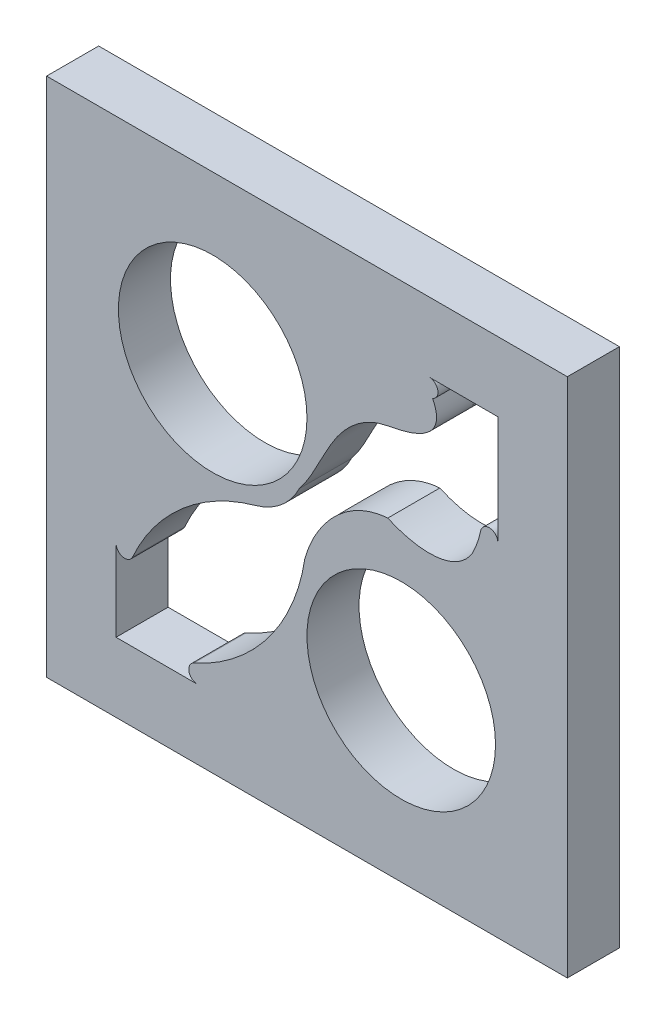
from build123d import *

# Parameters (mm, degrees)
CROQUIS1_W              = 30
CROQUIS1_H              = 30
CROQUIS1_R              = 5.43144852
SALIENTE_EXTRUIR1_DEPTH = 3


with BuildPart() as part:
    # Croquis1 → Saliente-Extruir1 (new body)
    with BuildSketch(Plane.XY):
        Rectangle(CROQUIS1_W, CROQUIS1_H)
        with Locations((5.43144852, -5.43144852)):
            Circle(CROQUIS1_R, mode=Mode.SUBTRACT)
        with BuildLine():
            Line((-11, -11), (-11, -6.30958424))
            ThreePointArc((-11, -6.30958424), (-10.604257207, -6.798593887), (-10.043478261, -6.51351536))
            ThreePointArc((-10.043478261, -6.51351536), (-7.184032198, -2.669953099), (-2.962030371, -0.40630489))
            ThreePointArc((-2.962030371, -0.40630489), (-1.479948679, 0.371768463), (-0.44603831, 1.688200624))
            add(Edge.make_bspline(
                [(-0.44603831, 1.688200624), (0.600161472, 2.997780482), (1.259535405, 5.412607882), (3.723491408, 7.268772296), (6.075005948, 7.554534112), (8.017011232, 8.499729242), (7.239010254, 10.03791357)],
                knots=[0, 0, 0, 0, 0.408369394, 0.584001697, 0.707826515, 1, 1, 1, 1], degree=3))
            ThreePointArc((7.239010254, 10.03791357), (7.538453023, 10.597357036), (7.048023, 11))
            Line((7.048023, 11), (11, 11))
            Line((11, 11), (11, 4.715933429))
            ThreePointArc((11, 4.715933429), (10.551626523, 5.213260989), (10.010661191, 4.8186346))
            ThreePointArc((10.010661191, 4.8186346), (9.813510438, 4.116058971), (9.524664361, 3.445947877))
            add(Edge.make_bspline(
                [(4.653277623, 2.773397026), (6.138085687, 2.096565381), (8.467088589, 1.756469214), (9.524664361, 3.445947877)],
                knots=[0, 0, 0, 0, 1, 1, 1, 1], degree=3))
            add(Edge.make_bspline(
                [(-0.124019497, -1.647133295), (0.48560807, 0.564599921), (2.28878007, 2.613788972), (4.653277623, 2.773397026)],
                knots=[0.123819996, 0.123819996, 0.123819996, 0.123819996, 1, 1, 1, 1], degree=3))
            ThreePointArc((-0.124019497, -1.647133295), (-0.206307312, -2.120424053), (-0.309181236, -2.589670665))
            ThreePointArc((-0.309181236, -2.589670665), (-2.545566455, -7.037226259), (-6.51351536, -10.043478261))
            ThreePointArc((-6.51351536, -10.043478261), (-6.798593887, -10.604257207), (-6.30958424, -11))
            Line((-6.30958424, -11), (-11, -11))
        make_face(mode=Mode.SUBTRACT)
        with Locations((-5.43144852, 5.43144852)):
            Circle(CROQUIS1_R, mode=Mode.SUBTRACT)
    extrude(amount=SALIENTE_EXTRUIR1_DEPTH)


solid = part.part
